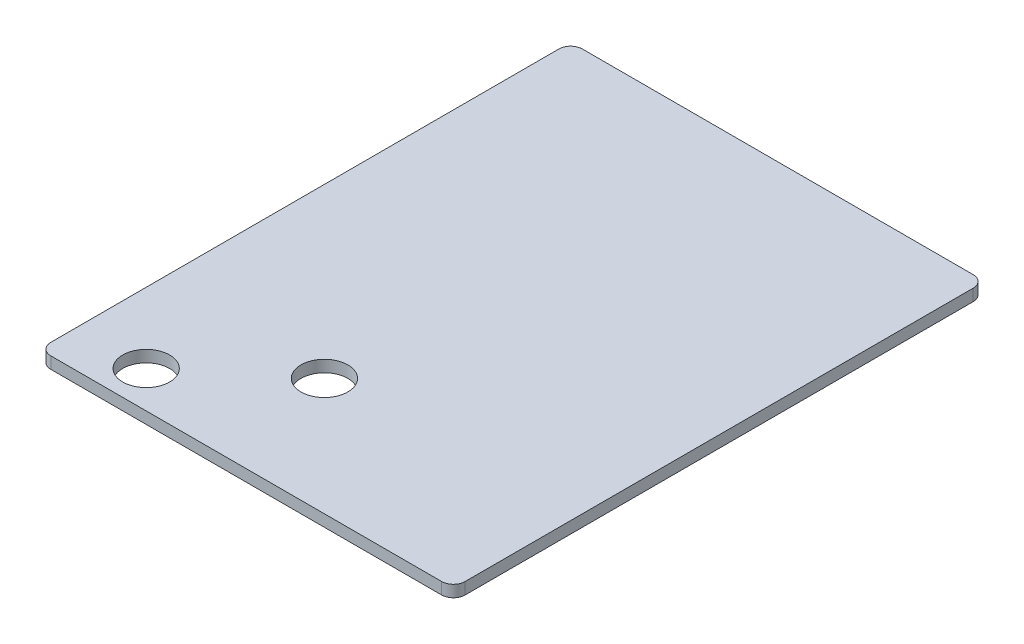
from build123d import *

# Parameters (mm, degrees)
ESQUISSE1_W             = 106
ESQUISSE1_H             = 136
BOSS_EXTRU_1_DEPTH      = 3
CONG_1_R                = 3
ESQUISSE2_R             = 6
ENL_V_MAT_EXTRU_1_DEPTH = 10


with BuildPart() as part:
    # Esquisse1 → Boss.-Extru.1 (new body)
    with BuildSketch(Plane(origin=(0, 0, 0), x_dir=(1, 0, 0), z_dir=(0, 1, 0))):
        Rectangle(ESQUISSE1_W, ESQUISSE1_H)
    extrude(amount=BOSS_EXTRU_1_DEPTH)

    # Congé1
    cong_1_edges = [part.edges().sort_by_distance(p)[0] for p in [
        (53, 1.5, 68),
        (-53, 1.5, 68),
        (-53, 1.5, -68),
        (53, 1.5, -68),
    ]]
    fillet(cong_1_edges, radius=CONG_1_R)

    # Esquisse2 → Enlèv. mat.-Extru.1 (cut)
    with BuildSketch(Plane(origin=(0, 3, 0), x_dir=(1, 0, 0), z_dir=(0, 1, 0))):
        with Locations((-35, -58.6)):
            Circle(ESQUISSE2_R)
        with Locations((-10, -38)):
            Circle(ESQUISSE2_R)
    extrude(amount=-ENL_V_MAT_EXTRU_1_DEPTH, mode=Mode.SUBTRACT)


solid = part.part
